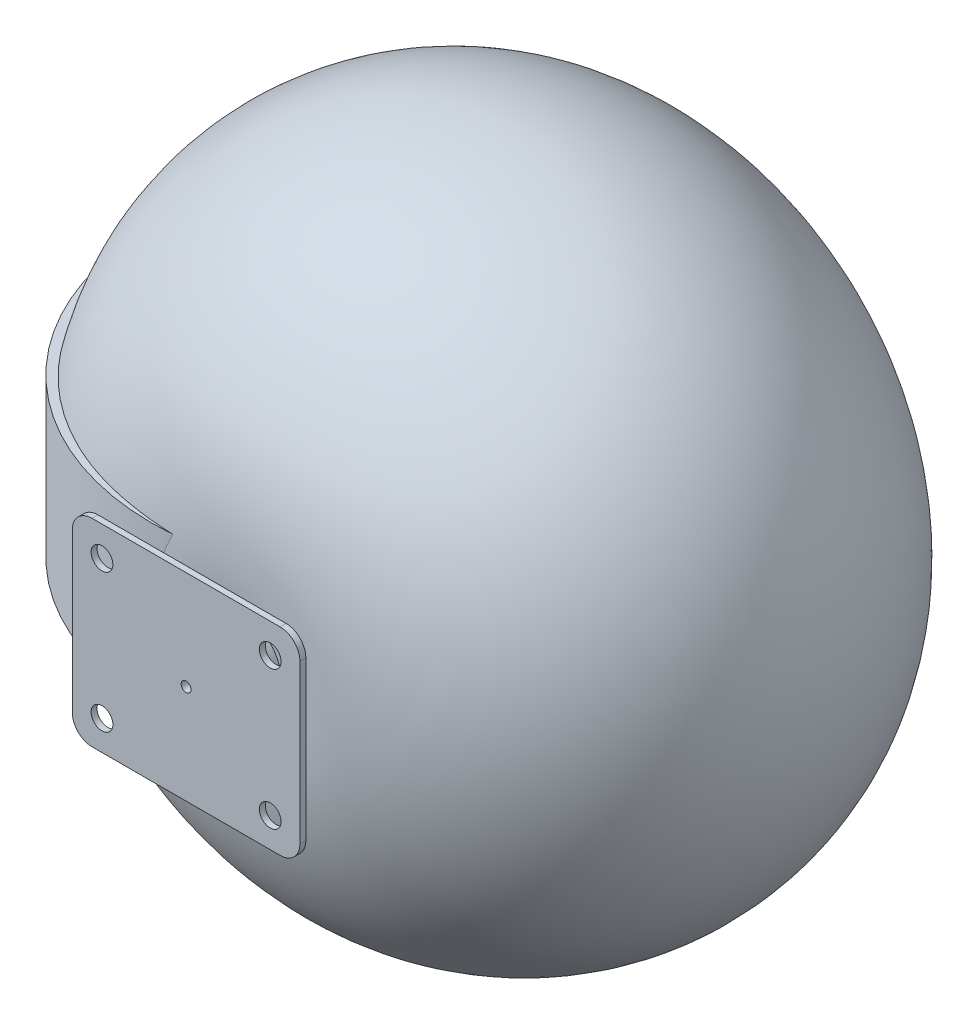
from build123d import *

# Parameters (mm, degrees)
SKIZZE1_W                       = 115
SKIZZE1_H                       = 100
AUFSATZ_LINEAR_AUSTRAGEN1_DEPTH = 3
SKIZZE2_R                       = 5.5
SCHNITT_LINEAR_AUSTRAGEN1_DEPTH = 5
VERRUNDUNG1_R                   = 10
SKIZZE3_R                       = 2.5
SCHNITT_LINEAR_AUSTRAGEN2_DEPTH = 10
SKIZZE4_R                       = 25
SKIZZE4_R_2                     = 2.5
AUFSATZ_LINEAR_AUSTRAGEN2_DEPTH = 150
SKIZZE5_R                       = 130
AUFSATZ_LINEAR_AUSTRAGEN3_DEPTH = 40
SKIZZE7_R                       = 130
AUFSATZ_LINEAR_AUSTRAGEN4_DEPTH = 80


with BuildPart() as part:
    # Skizze1 → Aufsatz-Linear austragen1 (new body)
    with BuildSketch(Plane.XY):
        Rectangle(SKIZZE1_W, SKIZZE1_H)
    extrude(amount=AUFSATZ_LINEAR_AUSTRAGEN1_DEPTH)

    # Skizze2 → Schnitt-Linear austragen1 (cut)
    with BuildSketch(Plane.XY.offset(3)):
        with Locations((-42.5, 35)):
            Circle(SKIZZE2_R)
        with Locations((42.5, 35)):
            Circle(SKIZZE2_R)
        with Locations((42.5, -35)):
            Circle(SKIZZE2_R)
        with Locations((-42.5, -35)):
            Circle(SKIZZE2_R)
    extrude(amount=-SCHNITT_LINEAR_AUSTRAGEN1_DEPTH, mode=Mode.SUBTRACT)

    # Verrundung1
    verrundung1_edges = [part.edges().sort_by_distance(p)[0] for p in [
        (-57.5, 50, 1.5),
        (57.5, 50, 1.5),
        (57.5, -50, 1.5),
        (-57.5, -50, 1.5),
    ]]
    fillet(verrundung1_edges, radius=VERRUNDUNG1_R)

    # Skizze3 → Schnitt-Linear austragen2 (cut)
    with BuildSketch(Plane(origin=(0, 0, 0), x_dir=(-1, 0, 0), z_dir=(0, 0, -1))):
        Circle(SKIZZE3_R)
    extrude(amount=-SCHNITT_LINEAR_AUSTRAGEN2_DEPTH, mode=Mode.SUBTRACT)

    # Skizze4 → Aufsatz-Linear austragen2 (add)
    with BuildSketch(Plane(origin=(0, 0, 0), x_dir=(-1, 0, 0), z_dir=(0, 0, -1))):
        with Locations(Location((0, 0, 0), (0, 0, 180))):  # turned: the seam where the file's is
            Circle(SKIZZE4_R)
        Circle(SKIZZE4_R_2, mode=Mode.SUBTRACT)
    extrude(amount=AUFSATZ_LINEAR_AUSTRAGEN2_DEPTH)

    # Skizze5 → Aufsatz-Linear austragen3 (add, symmetric)
    with BuildSketch(Plane(origin=(0, 0, 0), x_dir=(1, 0, 0), z_dir=(0, 1, 0))):
        with Locations(Location((-40, 150, 0), (0, 0, 270))):  # turned: the seam where the file's is
            Circle(SKIZZE5_R)
    extrude(amount=AUFSATZ_LINEAR_AUSTRAGEN3_DEPTH, both=True)

    # Skizze6 → Rotation3 (revolve)
    with BuildSketch(Plane(origin=(0, 0, 0), x_dir=(1, 0, 0), z_dir=(0, 1, 0))):
        with BuildLine():
            Line((0, 273.693169), (0, 26.306831))
            ThreePointArc((0, 26.306831), (-170, 150), (0, 273.693169))
        make_face()
    revolve(axis=Axis((0, 0, 0), (0, 0, -1)))

    # Skizze7 → Aufsatz-Linear austragen4 (add)
    with BuildSketch(Plane.XZ.offset(40)):
        with Locations((-40, -150)):
            Circle(SKIZZE7_R)
    extrude(amount=-AUFSATZ_LINEAR_AUSTRAGEN4_DEPTH)


solid = part.part
